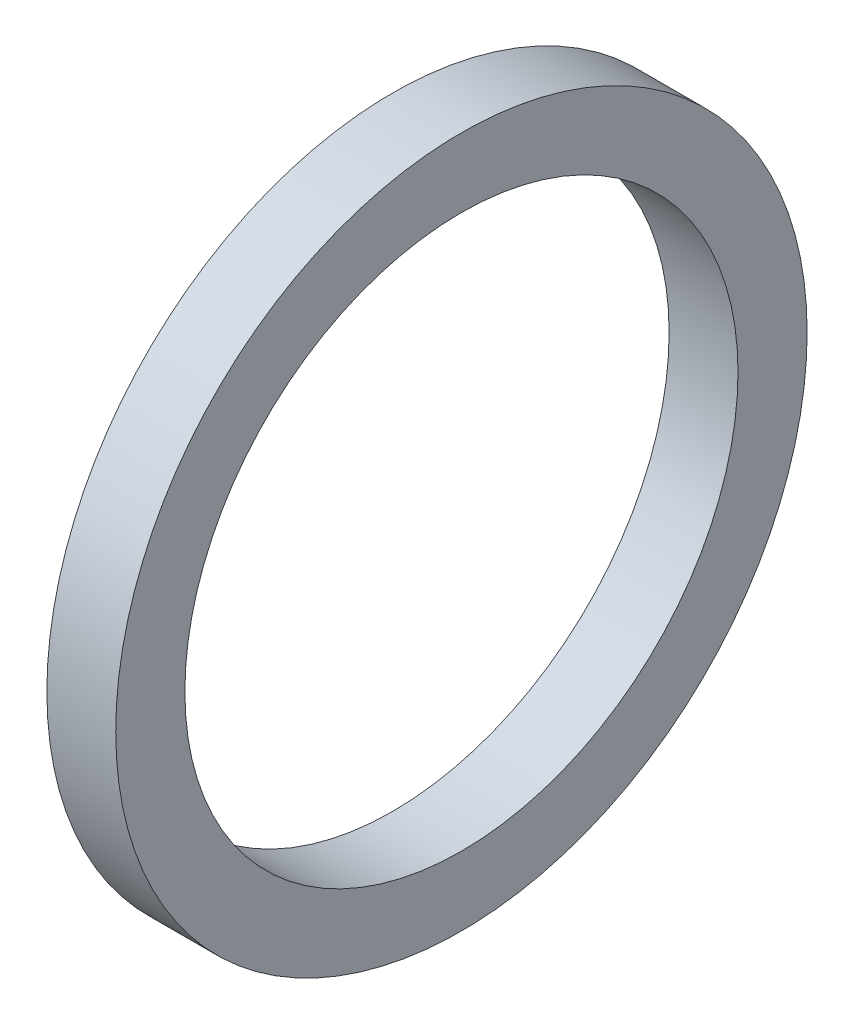
from build123d import *

# Parameters (mm, degrees)
SKETCH3_W = 9.959999892
SKETCH3_H = 9.999999939


with BuildPart() as part:
    # Sketch3 → Revolve1 (revolve)
    with BuildSketch(Plane.XY):
        with Locations((14.631549985, 44.99999998)):
            Rectangle(SKETCH3_W, SKETCH3_H)
    revolve(axis=Axis((0, 0, 0), (1, 0, 0)))


solid = part.part
